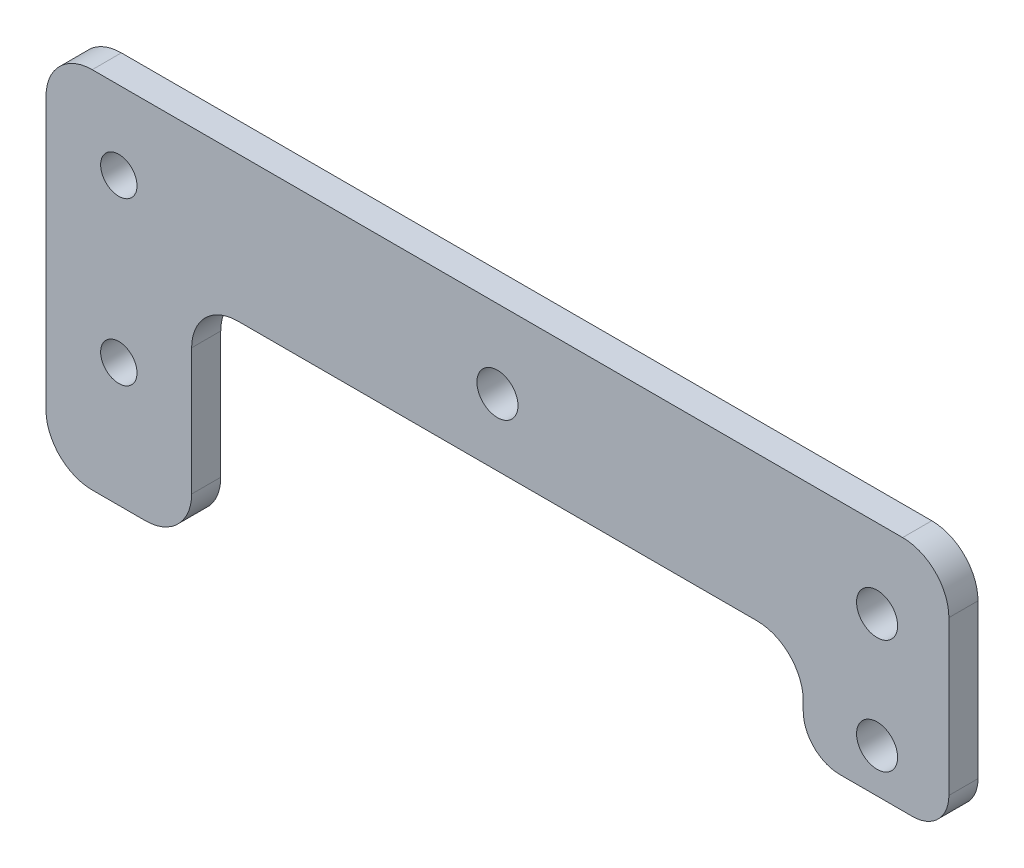
from build123d import *

# Parameters (mm, degrees)
CROQUIS1_R              = 2.5
CROQUIS1_R_2            = 2.821368504
SALIENTE_EXTRUIR1_DEPTH = 4


with BuildPart() as part:
    # Croquis1 → Saliente-Extruir1 (new body)
    with BuildSketch(Plane.XY):
        with BuildLine():
            Line((26.393375205, 6.699416954), (97.693375205, 6.699416954))
            ThreePointArc((97.693375205, 6.699416954), (102.183503265, 4.839545014), (104.043375205, 0.349416954))
            Line((104.043375205, 0.349416954), (104.043375205, -0.895643676))
            ThreePointArc((104.043375205, -0.895643676), (105.507841299, -4.431177582), (109.043375205, -5.895643676))
            Line((109.043375205, -5.895643676), (119.043375205, -5.895643676))
            ThreePointArc((119.043375205, -5.895643676), (122.578909111, -4.431177582), (124.043375205, -0.895643676))
            Line((124.043375205, -0.895643676), (124.043375205, 6.604356324))
            Line((124.043375205, 6.604356324), (124.043375205, 20.254356324))
            ThreePointArc((124.043375205, 20.254356324), (122.183503265, 24.744484385), (117.693375205, 26.604356324))
            Line((117.693375205, 26.604356324), (6.393375205, 26.604356324))
            ThreePointArc((6.393375205, 26.604356324), (1.903247144, 24.744484385), (0.043375205, 20.254356324))
            Line((0.043375205, 20.254356324), (0.043375205, 6.604356324))
            Line((0.043375205, 6.604356324), (0.043375205, -17.045643676))
            ThreePointArc((0.043375205, -17.045643676), (1.903247144, -21.535771736), (6.393375205, -23.395643676))
            Line((6.393375205, -23.395643676), (13.693375205, -23.395643676))
            ThreePointArc((13.693375205, -23.395643676), (18.183503265, -21.535771736), (20.043375205, -17.045643676))
            Line((20.043375205, -17.045643676), (20.043375205, 0.349416954))
            ThreePointArc((20.043375205, 0.349416954), (21.903247144, 4.839545014), (26.393375205, 6.699416954))
        make_face()
        with Locations((10.043375205, 15.866498333)):
            Circle(CROQUIS1_R, mode=Mode.SUBTRACT)
        with Locations((114.183375205, 15.771437703)):
            Circle(CROQUIS1_R_2, mode=Mode.SUBTRACT)
        with Locations((10.043375205, -6.395643676)):
            Circle(CROQUIS1_R, mode=Mode.SUBTRACT)
        with Locations((62.043375205, 15.866498333)):
            Circle(CROQUIS1_R_2, mode=Mode.SUBTRACT)
        with Locations((114.183375205, 0.104356324)):
            Circle(CROQUIS1_R_2, mode=Mode.SUBTRACT)
    extrude(amount=SALIENTE_EXTRUIR1_DEPTH)


solid = part.part
